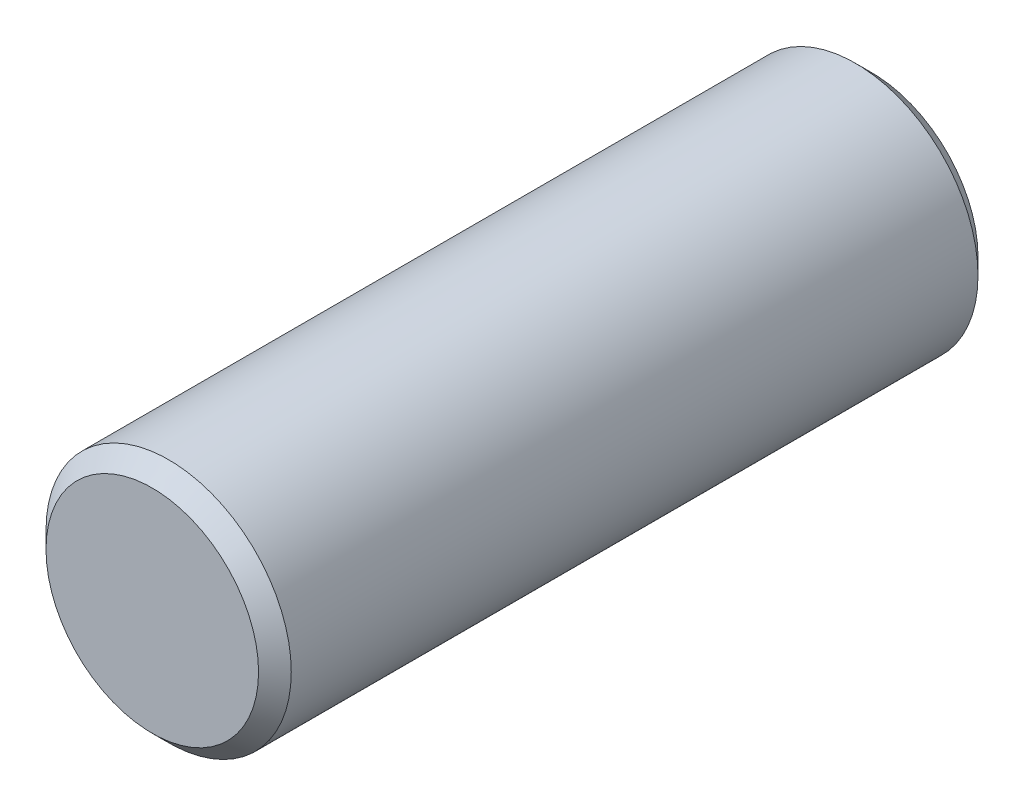
from build123d import *

# Parameters (mm, degrees)
SKETCH1_R           = 7.5
BOSS_EXTRUDE1_DEPTH = 44
CHAMFER1_SIZE       = 1
CHAMFER2_SIZE       = 1


with BuildPart() as part:
    # Sketch1 → Boss-Extrude1 (new body)
    with BuildSketch(Plane.XY):
        Circle(SKETCH1_R)
    extrude(amount=BOSS_EXTRUDE1_DEPTH)

    # Chamfer1
    chamfer1_edges = [part.edges().sort_by_distance(p)[0] for p in [
        (-7.5, 0, 0),
    ]]
    chamfer(chamfer1_edges, length=CHAMFER1_SIZE)

    # Chamfer2
    chamfer2_edges = [part.edges().sort_by_distance(p)[0] for p in [
        (-7.5, 0, 44),
    ]]
    chamfer(chamfer2_edges, length=CHAMFER2_SIZE)


solid = part.part
